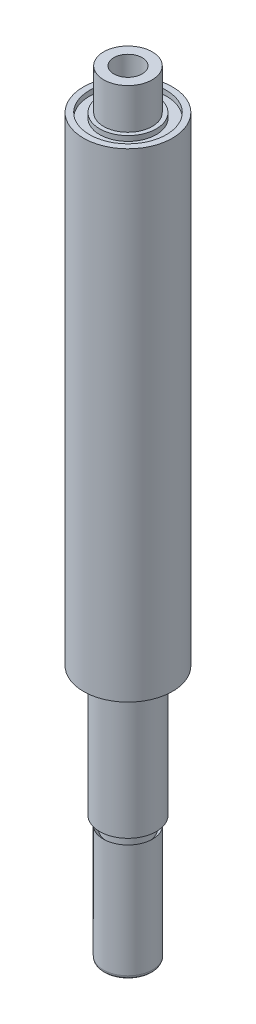
from build123d import *


with BuildPart() as part:
    # Croquis1 → Revolución1 (revolve)
    with BuildSketch(Plane.XY):
        with BuildLine():
            Line((3.5, 46.282828283), (6, 46.282828283))
            Line((6, 46.282828283), (6, 36.282828283))
            Line((6, 36.282828283), (7, 36.282828283))
            Line((7, 36.282828283), (7, 35.032828283))
            Line((7, 35.032828283), (9.5, 35.032828283))
            Line((9.5, 35.032828283), (9.5, 36.282828283))
            Line((9.5, 36.282828283), (11, 36.282828283))
            Line((11, 36.282828283), (11, -82.217171717))
            Line((11, -82.217171717), (7, -82.217171717))
            Line((7, -82.217171717), (7, -114.217171717))
            Line((7, -114.217171717), (5.161616162, -114.217171717))
            Line((5.161616162, -114.217171717), (5.161616162, -117.217171717))
            Line((5.161616162, -117.217171717), (6.080808081, -116.297979798))
            Line((6.080808081, -116.297979798), (6.080808081, -144.297979798))
            ThreePointArc((6.080808081, -144.297979798), (5.811583001, -144.947946637), (5.161616162, -145.217171717))
            Line((5.161616162, -145.217171717), (0, -145.217171717))
            Line((0, -145.217171717), (0, 21.282828283))
            Line((0, 21.282828283), (3.5, 21.282828283))
            Line((3.5, 21.282828283), (3.5, 46.282828283))
        make_face()
    revolve(axis=Axis((0, 29.484848485, 0), (0, -1, 0)))


solid = part.part
